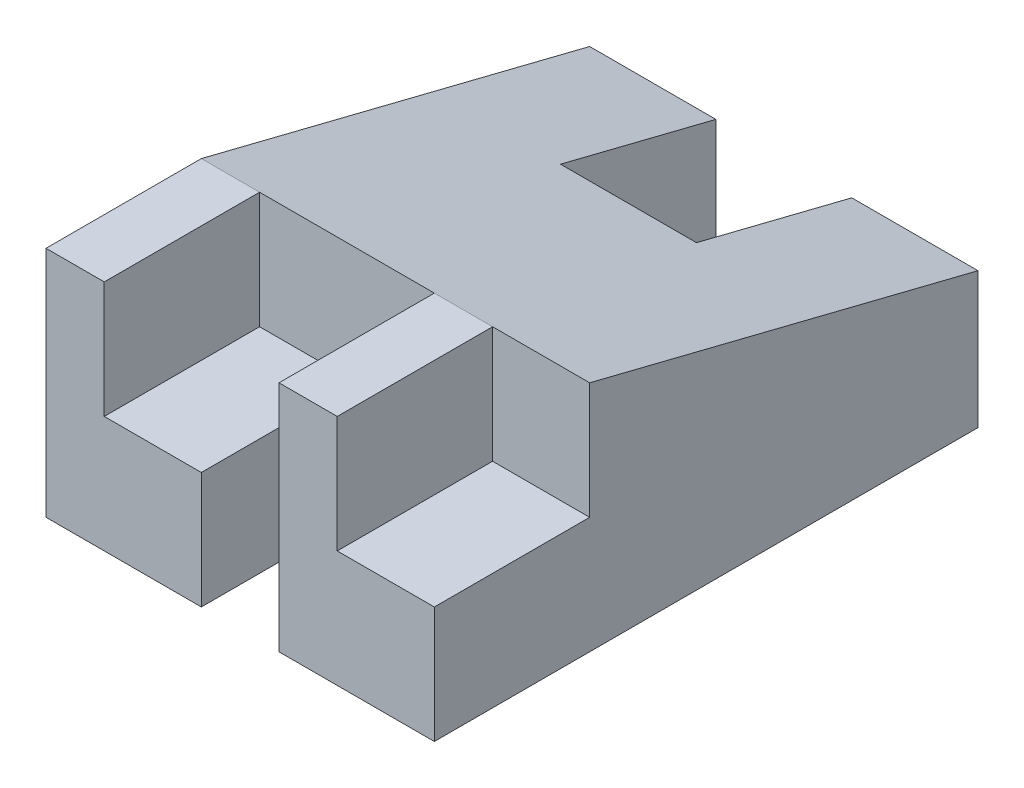
from build123d import *

# Parameters (mm, degrees)
BOSS_EXTRUDE1_DEPTH = 31.75
SKETCH2_W           = 12.7
SKETCH2_H           = 25.4
CUT_EXTRUDE1_DEPTH  = 63.5
SKETCH3_W           = 15.875
SKETCH3_H           = 25.4
CUT_EXTRUDE2_DEPTH  = 19.05
SKETCH4_W           = 22.225
SKETCH4_H           = 25.4
CUT_EXTRUDE3_DEPTH  = 39.1


with BuildPart() as part:
    # Sketch1 → Boss-Extrude1 (new body, symmetric)
    with BuildSketch(Plane(origin=(0, 0, 0), x_dir=(0, 0, -1), z_dir=(1, 0, 0))):
        Polygon((-52.000801282, -26.427804487), (36.899198718, -26.427804487), (36.899198718, -4.202804487), (-26.600801282, 11.672195513), (-52.000801282, 11.672195513), align=None)
    extrude(amount=BOSS_EXTRUDE1_DEPTH, both=True)

    # Sketch2 → Cut-Extrude1 (cut)
    with BuildSketch(Plane(origin=(0, 11.672195513, 0), x_dir=(1, 0, 0), z_dir=(0, 1, 0))):
        with Locations((0, -39.300801282)):
            Rectangle(SKETCH2_W, SKETCH2_H)
    extrude(amount=-CUT_EXTRUDE1_DEPTH, mode=Mode.SUBTRACT)

    # Sketch3 → Cut-Extrude2 (cut)
    with BuildSketch(Plane(origin=(0, 11.672195513, 0), x_dir=(1, 0, 0), z_dir=(0, 1, 0))):
        with Locations((23.8125, -39.300801282)):
            Rectangle(SKETCH3_W, SKETCH3_H)
        with Locations((-14.2875, -39.300801282)):
            Rectangle(SKETCH3_W, SKETCH3_H)
    extrude(amount=-CUT_EXTRUDE2_DEPTH, mode=Mode.SUBTRACT)

    # Sketch4 → Cut-Extrude3 (cut, through all)
    with BuildSketch(Plane.XZ.offset(26.427804487)):
        with Locations((0, -24.199198718)):
            Rectangle(SKETCH4_W, SKETCH4_H)
    extrude(amount=-CUT_EXTRUDE3_DEPTH, mode=Mode.SUBTRACT)


solid = part.part
